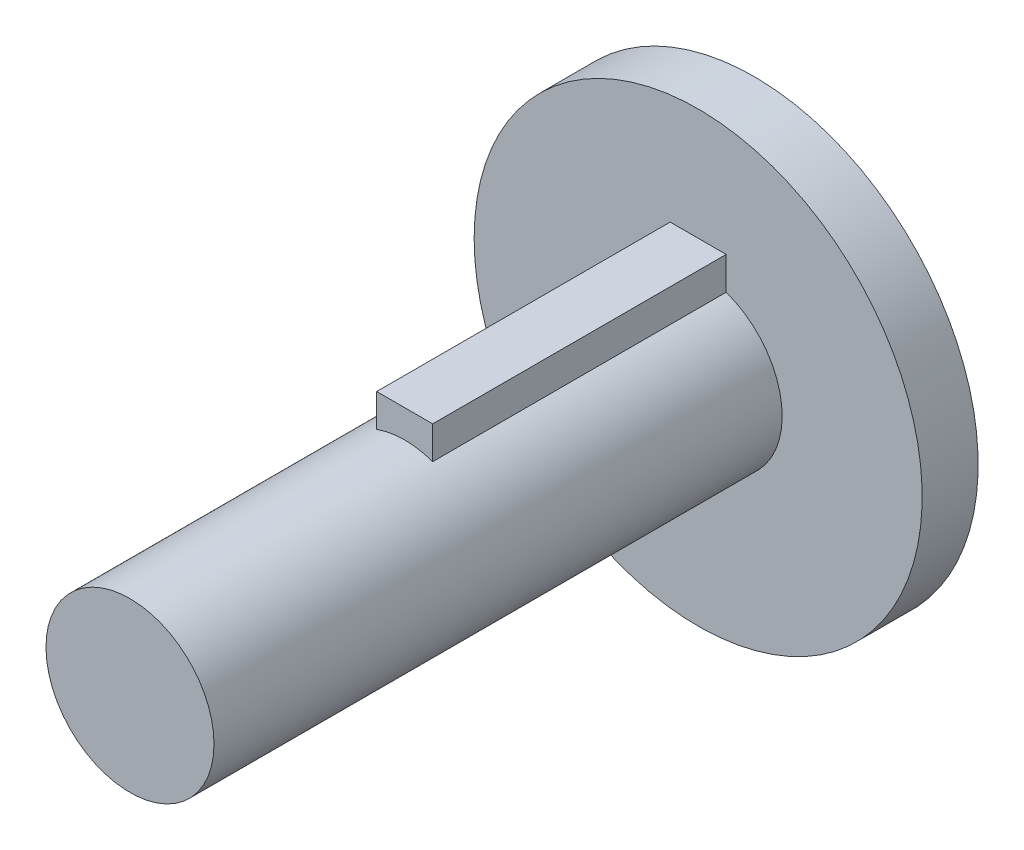
from build123d import *

# Parameters (mm, degrees)
SKETCH1_R           = 3
BOSS_EXTRUDE1_DEPTH = 20.29
SKETCH2_W           = 2
SKETCH2_H           = 1.17
BOSS_EXTRUDE2_DEPTH = 10.48
SKETCH3_R           = 8
BOSS_EXTRUDE3_DEPTH = 2


with BuildPart() as part:
    # Sketch1 → Boss-Extrude1 (new body)
    with BuildSketch(Plane.XY):
        Circle(SKETCH1_R)
    extrude(amount=BOSS_EXTRUDE1_DEPTH)

    # Sketch2 → Boss-Extrude2 (add)
    with BuildSketch(Plane(origin=(0, 0, 0), x_dir=(-1, 0, 0), z_dir=(0, 0, -1))):
        with Locations((0, 3.413427125)):
            Rectangle(SKETCH2_W, SKETCH2_H)
    extrude(amount=-BOSS_EXTRUDE2_DEPTH)

    # Sketch3 → Boss-Extrude3 (add)
    with BuildSketch(Plane(origin=(0, 0, 0), x_dir=(-1, 0, 0), z_dir=(0, 0, -1))):
        Circle(SKETCH3_R)
    extrude(amount=BOSS_EXTRUDE3_DEPTH)


solid = part.part
